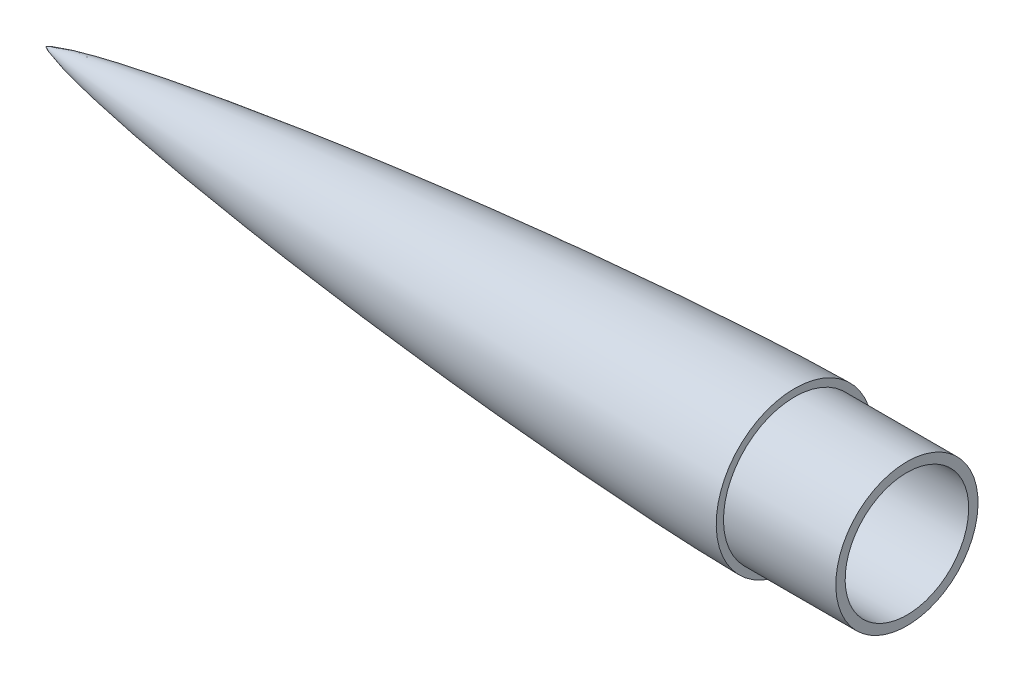
from build123d import *


with BuildPart() as part:
    # Sketch1 → Revolve1 (revolve)
    with BuildSketch(Plane.XY):
        with BuildLine():
            Line((-153.237304308, 33), (0, 33))
            Line((0, 33), (0, 38))
            Line((0, 38), (-60, 38))
            Line((-60, 38), (-60, 41.9))
            add(Edge.make_bspline(
                [(-460, 0), (-459.996067969, 0.009726018), (-459.985785217, 0.02780424), (-459.957005025, 0.058902426), (-459.91205001, 0.100212526), (-459.856244624, 0.143432876), (-459.775484012, 0.200311335), (-459.683468726, 0.258611779), (-459.579785862, 0.319460144), (-459.418939028, 0.407565244), (-459.180873374, 0.528192028), (-458.777616559, 0.714285403), (-458.057255833, 1.0123178), (-456.771507758, 1.483474784), (-454.40722191, 2.241844729), (-449.963807437, 3.474543289), (-442.199798746, 5.321162346), (-428.97101079, 8.026665147), (-410.788345474, 11.220424569), (-388.73281348, 14.634427911), (-364.190784603, 18.036918263), (-339.610222302, 21.14585558), (-315.00008174, 24.010782423), (-290.366278158, 26.663429751), (-265.712399697, 29.122407259), (-241.041086643, 31.39940616), (-216.354099064, 33.499758191), (-191.652773648, 35.424046474), (-170.027352253, 36.949507855), (-151.483266154, 38.137109734), (-136.024634606, 39.040436446), (-123.654619224, 39.707777336), (-111.281493824, 40.315125483), (-100.452283743, 40.78818035), (-91.168142985, 41.145909221), (-83.707200452, 41.397635934), (-78.07036158, 41.56649526), (-73.345484372, 41.688284291), (-69.532872299, 41.7726603), (-66.355463671, 41.830361619), (-63.813396377, 41.870139432), (-61.906740046, 41.888745562), (-60.635587942, 41.9), (-60, 41.9)],
                knots=[0, 0, 0, 0, 0, 0.000103786, 0.000207572, 0.000415145, 0.000608587, 0.000802029, 0.001188912, 0.00149546, 0.001802008, 0.002622229, 0.003837599, 0.005902992, 0.009538441, 0.016211619, 0.02847806, 0.051665811, 0.088742351, 0.150226851, 0.211711468, 0.273196132, 0.334680786, 0.396165341, 0.457649956, 0.519134579, 0.580619211, 0.642103793, 0.703588429, 0.765073013, 0.795815252, 0.826557492, 0.857299765, 0.888042038, 0.918784374, 0.934155543, 0.949526711, 0.962145033, 0.974763355, 0.981072517, 0.987381678, 0.993690839, 1, 1, 1, 1, 1], degree=4))
            Line((-460, 0), (-442.793127384, 0))
            ThreePointArc((-442.793127384, 0), (-298.586447591, 21.512226611), (-153.237304308, 33))
        make_face()
    revolve(axis=Axis((-442.793127384, 0, 0), (-1, 0, 0)))


solid = part.part
